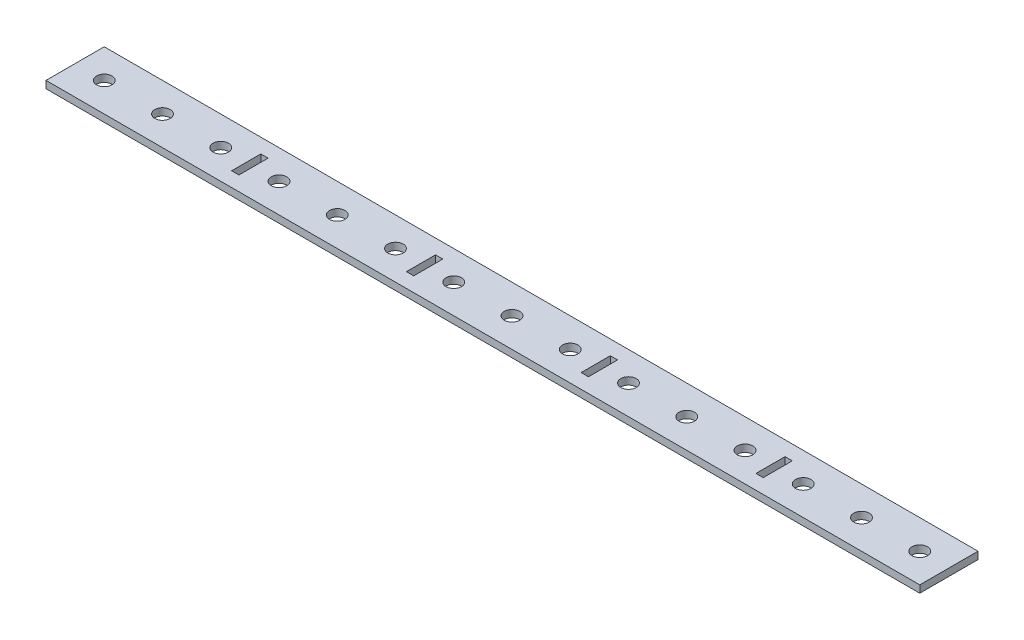
from build123d import *

# Parameters (mm, degrees)
SKETCH1_W                             = 381
SKETCH1_H                             = 25.4
BOSS_EXTRUDE1_DEPTH                   = 3.175
F_1_4_CLEARANCE_FIRST_MOUNTING_HOLE_D = 6.7564
PEDAL_BOX_MOUNTING_HOLE_PATTERN_COUNT = 15
PEDAL_BOX_MOUNTING_HOLE_PATTERN_PITCH = 25.4
SKETCH8_W                             = 3.175
SKETCH8_H                             = 12.7
SUPPORT_TAB_WELDING_CUT_DEPTH         = 3.175
SUPPORT_TAB_WELDING_CUT_PATTERN_COUNT = 4
SUPPORT_TAB_WELDING_CUT_PATTERN_PITCH = 76.2


with BuildPart() as part:
    # Sketch1 → Boss-Extrude1 (new body)
    with BuildSketch(Plane(origin=(0, 0, 0), x_dir=(1, 0, 0), z_dir=(0, 1, 0))):
        with Locations((190.5, 12.7)):
            Rectangle(SKETCH1_W, SKETCH1_H)
    extrude(amount=BOSS_EXTRUDE1_DEPTH)

    # 1/4 Clearance First Mounting Hole (through all)
    with Locations(Plane(origin=(0, 3.175, 0), x_dir=(1, 0, 0), z_dir=(0, 1, 0))):
        with Locations((12.7, 12.7)):
            f_1_4_clearance_first_mounting_hole = Hole(F_1_4_CLEARANCE_FIRST_MOUNTING_HOLE_D / 2)

    # Pedal Box Mounting Hole Pattern: 1/4 Clearance First Mounting Hole ×15
    with Locations(*[(i * PEDAL_BOX_MOUNTING_HOLE_PATTERN_PITCH, 0, 0) for i in range(1, PEDAL_BOX_MOUNTING_HOLE_PATTERN_COUNT)]):
        add(f_1_4_clearance_first_mounting_hole, mode=Mode.SUBTRACT)

    # Sketch8 → Support Tab Welding Cut (cut)
    with BuildSketch(Plane(origin=(0, 3.175, 0), x_dir=(1, 0, 0), z_dir=(0, 1, 0))):
        with Locations((76.2, 12.7)):
            Rectangle(SKETCH8_W, SKETCH8_H)
    support_tab_welding_cut = extrude(amount=-SUPPORT_TAB_WELDING_CUT_DEPTH, mode=Mode.SUBTRACT)

    # Support Tab Welding Cut Pattern: Support Tab Welding Cut ×4
    with Locations(*[(i * SUPPORT_TAB_WELDING_CUT_PATTERN_PITCH, 0, 0) for i in range(1, SUPPORT_TAB_WELDING_CUT_PATTERN_COUNT)]):
        add(support_tab_welding_cut, mode=Mode.SUBTRACT)


solid = part.part
